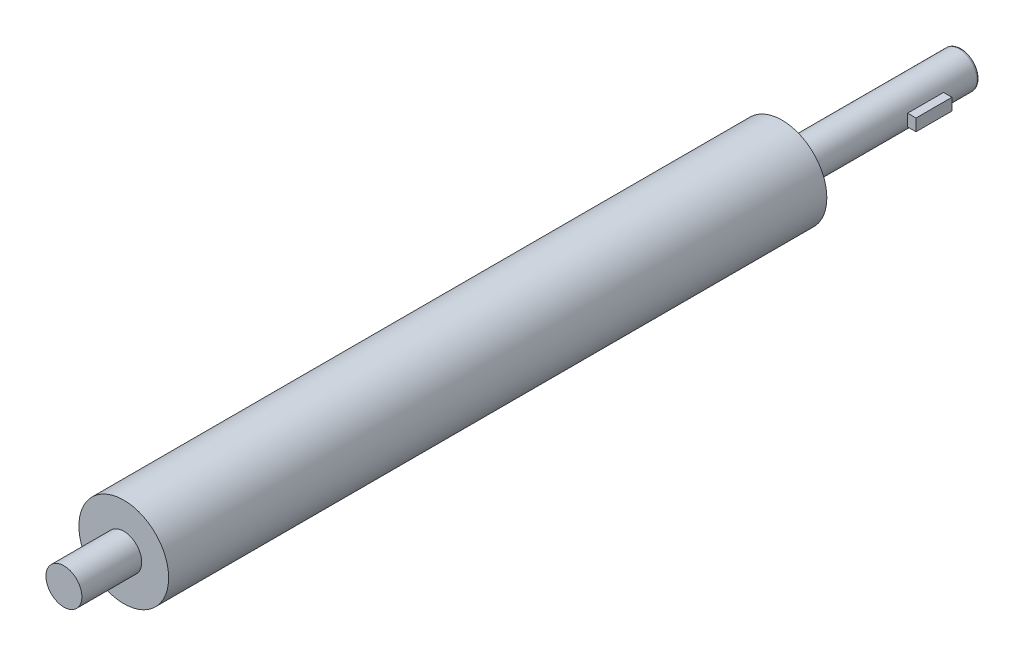
from build123d import *

# Parameters (mm, degrees)
SKETCH1_R           = 37.5
BOSS_EXTRUDE1_DEPTH = 550
SKETCH2_R           = 15
BOSS_EXTRUDE2_DEPTH = 50
SKETCH3_R           = 15
BOSS_EXTRUDE3_DEPTH = 150
SKETCH6_W           = 30
SKETCH6_H           = 10
BOSS_EXTRUDE4_DEPTH = 7
FILLET1_R           = 2


with BuildPart() as part:
    # Sketch1 → Boss-Extrude1 (new body)
    with BuildSketch(Plane.XY):
        Circle(SKETCH1_R)
    extrude(amount=BOSS_EXTRUDE1_DEPTH)

    # Sketch2 → Boss-Extrude2 (add)
    with BuildSketch(Plane.XY.offset(550)):
        Circle(SKETCH2_R)
    extrude(amount=BOSS_EXTRUDE2_DEPTH)

    # Sketch3 → Boss-Extrude3 (add)
    with BuildSketch(Plane(origin=(0, 0, 0), x_dir=(-1, 0, 0), z_dir=(0, 0, -1))):
        Circle(SKETCH3_R)
    extrude(amount=BOSS_EXTRUDE3_DEPTH)

    # Fillet1
    fillet1_edges = [part.edges().sort_by_distance(p)[0] for p in [
        (15, 0, -150),
    ]]
    fillet(fillet1_edges, radius=FILLET1_R)


with BuildPart() as body_2:
    # Sketch6 → Boss-Extrude4 (new body)
    with BuildSketch(Plane(origin=(15, 0, 0), x_dir=(0, 0, -1), z_dir=(1, 0, 0))):
        with Locations((105, 0)):
            Rectangle(SKETCH6_W, SKETCH6_H)
    extrude(amount=BOSS_EXTRUDE4_DEPTH)


solid = Compound([part.part, body_2.part])
